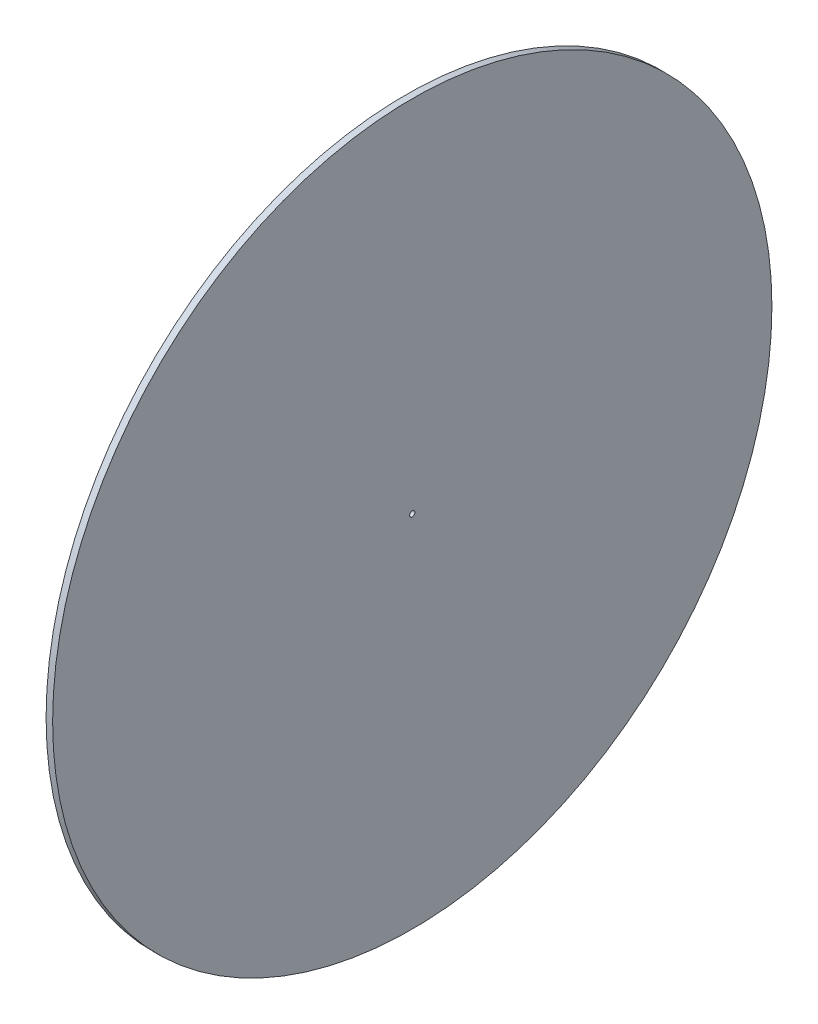
from build123d import *

# Parameters (mm, degrees)
ESQUISSE2_R             = 165
BOSS_EXTRU_1_DEPTH      = 3
ESQUISSE4_R             = 1.2
ENL_V_MAT_EXTRU_2_DEPTH = 10


with BuildPart() as part:
    # Esquisse2 → Boss.-Extru.1 (new body)
    with BuildSketch(Plane(origin=(0, 0, 0), x_dir=(0, 0, -1), z_dir=(1, 0, 0))):
        Circle(ESQUISSE2_R)
    extrude(amount=BOSS_EXTRU_1_DEPTH)

    # Esquisse4 → Enlèv. mat.-Extru.2 (cut)
    with BuildSketch(Plane(origin=(3, 0, 0), x_dir=(0, 0, -1), z_dir=(1, 0, 0))):
        Circle(ESQUISSE4_R)
    extrude(amount=-ENL_V_MAT_EXTRU_2_DEPTH, mode=Mode.SUBTRACT)


solid = part.part
